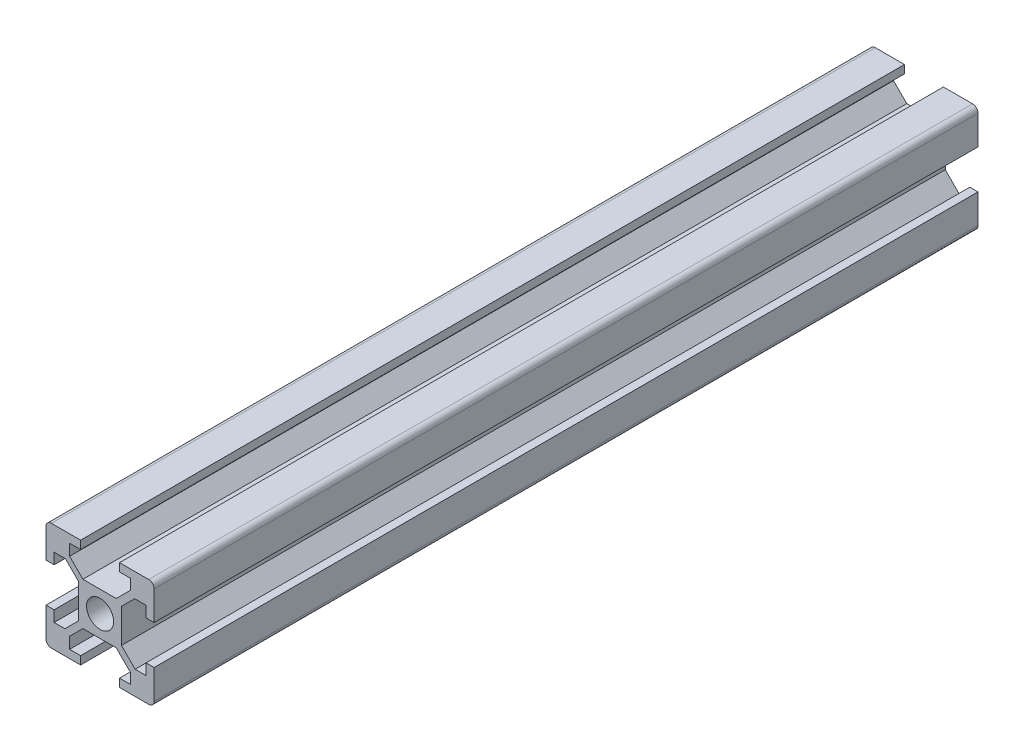
from build123d import *

# Parameters (mm, degrees)
SKETCH1_R           = 2.5
BOSS_EXTRUDE1_DEPTH = 482.6
SKETCH2_W           = 61.361470627
SKETCH2_H           = 380.25471835
CUT_EXTRUDE1_DEPTH  = 21


with BuildPart() as part:
    # Sketch1 → Boss-Extrude1 (new body)
    with BuildSketch(Plane.XY):
        with BuildLine():
            Line((-5.63, 10), (-9, 10))
            ThreePointArc((-9, 10), (-9.707106781, 9.707106781), (-10, 9))
            Line((-10, 9), (-10, 5.63))
            Line((-10, 5.63), (-10, 3.6))
            Line((-10, 3.6), (-8.5, 3.6))
            Line((-8.5, 3.6), (-8.5, 5.63))
            Line((-8.5, 5.63), (-6.402046573, 5.63))
            Line((-6.402046573, 5.63), (-3.95, 3.177953427))
            Line((-3.95, 3.177953427), (-3.95, -3.088580227))
            Line((-3.95, -3.088580227), (-6.491419773, -5.63))
            Line((-6.491419773, -5.63), (-8.5, -5.63))
            Line((-8.5, -5.63), (-8.5, -3.6))
            Line((-8.5, -3.6), (-10, -3.6))
            Line((-10, -3.6), (-10, -5.63))
            Line((-10, -5.63), (-10, -9))
            ThreePointArc((-10, -9), (-9.707106781, -9.707106781), (-9, -10))
            Line((-9, -10), (-5.63, -10))
            Line((-5.63, -10), (-3.6, -10))
            Line((-3.6, -10), (-3.6, -8.5))
            Line((-3.6, -8.5), (-5.63, -8.5))
            Line((-5.63, -8.5), (-5.63, -6.402046573))
            Line((-5.63, -6.402046573), (-3.177953427, -3.95))
            Line((-3.177953427, -3.95), (2.991333041, -3.95))
            Line((2.991333041, -3.95), (5.63, -6.588666959))
            Line((5.63, -6.588666959), (5.63, -8.5))
            Line((5.63, -8.5), (3.6, -8.5))
            Line((3.6, -8.5), (3.6, -10))
            Line((3.6, -10), (5.63, -10))
            Line((5.63, -10), (9, -10))
            ThreePointArc((9, -10), (9.707106781, -9.707106781), (10, -9))
            Line((10, -9), (10, -5.63))
            Line((10, -5.63), (10, -3.6))
            Line((10, -3.6), (8.5, -3.6))
            Line((8.5, -3.6), (8.5, -5.63))
            Line((8.5, -5.63), (6.491419773, -5.63))
            Line((6.491419773, -5.63), (3.95, -3.088580227))
            Line((3.95, -3.088580227), (3.95, 3.177953427))
            Line((3.95, 3.177953427), (6.402046573, 5.63))
            Line((6.402046573, 5.63), (8.5, 5.63))
            Line((8.5, 5.63), (8.5, 3.6))
            Line((8.5, 3.6), (10, 3.6))
            Line((10, 3.6), (10, 5.63))
            Line((10, 5.63), (10, 9))
            ThreePointArc((10, 9), (9.707106781, 9.707106781), (9, 10))
            Line((9, 10), (5.63, 10))
            Line((5.63, 10), (3.6, 10))
            Line((3.6, 10), (3.6, 8.5))
            Line((3.6, 8.5), (5.63, 8.5))
            Line((5.63, 8.5), (5.63, 6.588666959))
            Line((5.63, 6.588666959), (2.991333041, 3.95))
            Line((2.991333041, 3.95), (-3.177953427, 3.95))
            Line((-3.177953427, 3.95), (-5.63, 6.402046573))
            Line((-5.63, 6.402046573), (-5.63, 8.5))
            Line((-5.63, 8.5), (-3.6, 8.5))
            Line((-3.6, 8.5), (-3.6, 10))
            Line((-3.6, 10), (-5.63, 10))
        make_face()
        Circle(SKETCH1_R, mode=Mode.SUBTRACT)
    extrude(amount=BOSS_EXTRUDE1_DEPTH)

    # Sketch2 → Cut-Extrude1 (cut, through all)
    with BuildSketch(Plane(origin=(0, 10, 0), x_dir=(1, 0, 0), z_dir=(0, 1, 0))):
        with Locations((14.074869471, -342.527359175)):
            Rectangle(SKETCH2_W, SKETCH2_H)
    extrude(amount=-CUT_EXTRUDE1_DEPTH, mode=Mode.SUBTRACT)


solid = part.part
